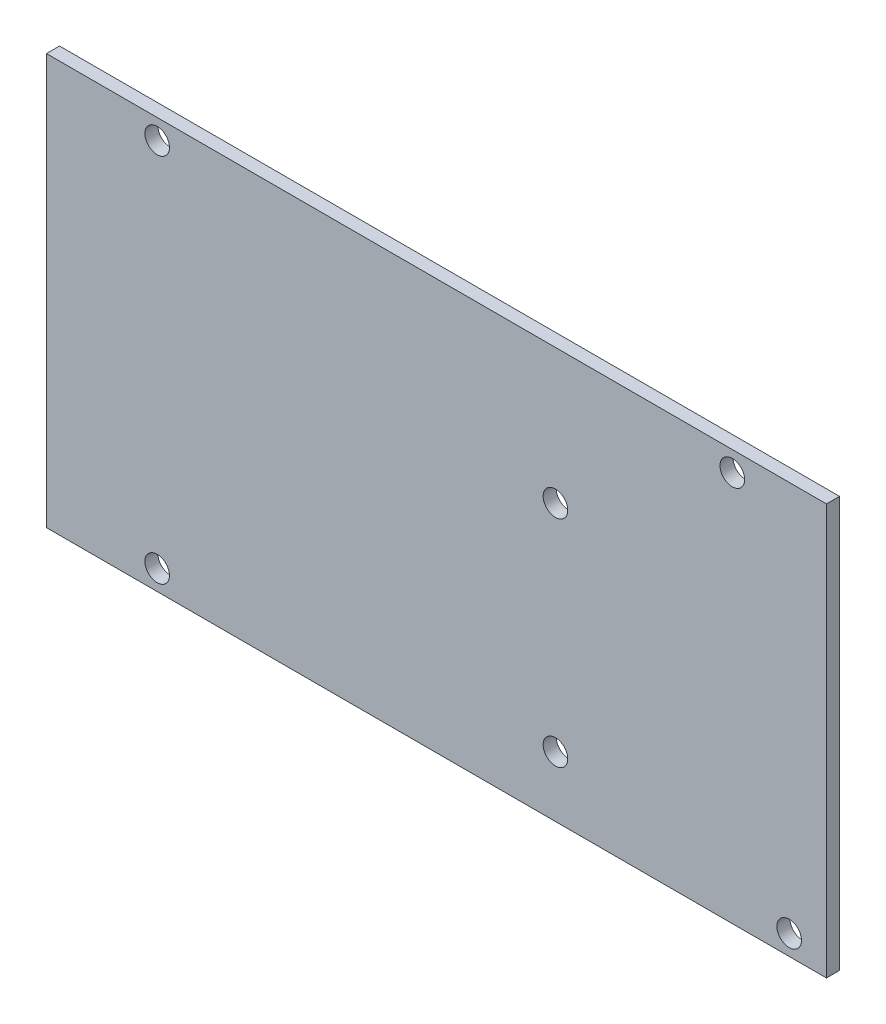
from build123d import *

# Parameters (mm, degrees)
SKETCH1_W           = 101.45
SKETCH1_H           = 53.4
SKETCH1_R           = 1.6
BOSS_EXTRUDE1_DEPTH = 1.7


with BuildPart() as part:
    # Sketch1 → Boss-Extrude1 (new body)
    with BuildSketch(Plane.XY):
        Rectangle(SKETCH1_W, SKETCH1_H)
        with Locations((-36.325, 24.1)):
            Circle(SKETCH1_R, mode=Mode.SUBTRACT)
        with Locations((-36.325, -24.1)):
            Circle(SKETCH1_R, mode=Mode.SUBTRACT)
        with Locations((15.475, -18.85)):
            Circle(SKETCH1_R, mode=Mode.SUBTRACT)
        with Locations((15.475, 9.15)):
            Circle(SKETCH1_R, mode=Mode.SUBTRACT)
        with Locations((38.475, 24.1)):
            Circle(SKETCH1_R, mode=Mode.SUBTRACT)
        with Locations((45.875, -24.1)):
            Circle(SKETCH1_R, mode=Mode.SUBTRACT)
    extrude(amount=BOSS_EXTRUDE1_DEPTH)


solid = part.part
